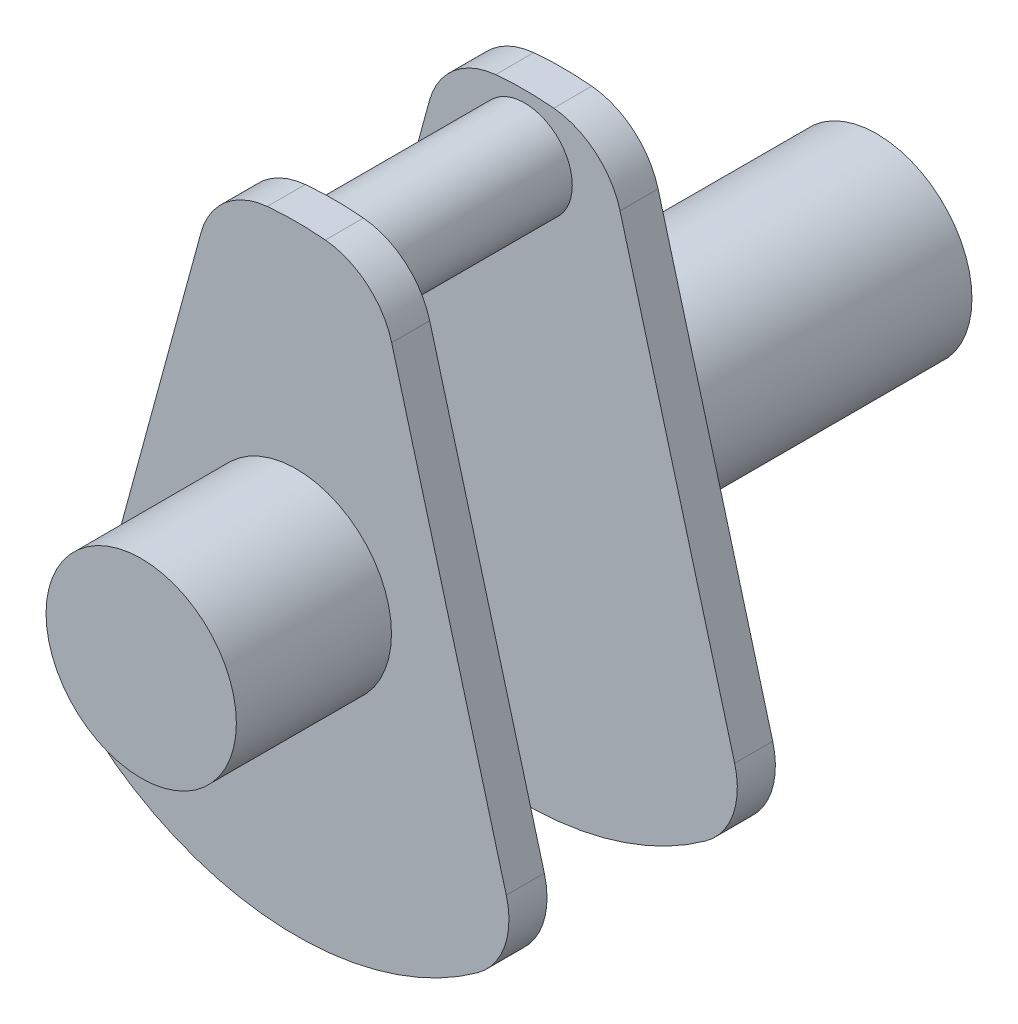
from build123d import *

# Parameters (mm, degrees)
BOSS_EXTRUDE1_DEPTH = 0.8
SKETCH2_R           = 1
BOSS_EXTRUDE2_DEPTH = 2
SKETCH3_R           = 2
BOSS_EXTRUDE3_DEPTH = 3.26
SKETCH4_R           = 2
BOSS_EXTRUDE4_DEPTH = 3.34
SKETCH5_W           = 0.1
SKETCH5_H           = 0.5
CUT_EXTRUDE1_DEPTH  = 0.1


with BuildPart() as part:
    # Sketch1 → Boss-Extrude1 (new body)
    with BuildSketch(Plane.XY):
        with BuildLine():
            Line((-2.003843202, 5.298536735), (-4.412682198, -3.552198604))
            ThreePointArc((-4.412682198, -3.552198604), (-4.377352827, -4.505653519), (-3.805602751, -5.269476986))
            ThreePointArc((-3.805602751, -5.269476986), (0, -6.5), (3.805602751, -5.269476986))
            ThreePointArc((3.805602751, -5.269476986), (4.377352827, -4.505653519), (4.412682198, -3.552198604))
            Line((4.412682198, -3.552198604), (2.003843202, 5.298536735))
            ThreePointArc((2.003843202, 5.298536735), (1.490188902, 6.102578835), (0.610204082, 6.471294382))
            ThreePointArc((0.610204082, 6.471294382), (0, 6.5), (-0.610204082, 6.471294382))
            ThreePointArc((-0.610204082, 6.471294382), (-1.490188902, 6.102578835), (-2.003843202, 5.298536735))
        make_face()
    extrude(amount=BOSS_EXTRUDE1_DEPTH)

    # Sketch2 → Boss-Extrude2 (add)
    with BuildSketch(Plane.XY.offset(0.8)):
        with Locations((0, 5.26)):
            Circle(SKETCH2_R)
    extrude(amount=BOSS_EXTRUDE2_DEPTH)

    # Sketch3 → Boss-Extrude3 (add)
    with BuildSketch(Plane(origin=(0, 0, 0), x_dir=(-1, 0, 0), z_dir=(0, 0, -1))):
        Circle(SKETCH3_R)
    extrude(amount=BOSS_EXTRUDE3_DEPTH)

    # Mirror1: part across plane


with BuildPart() as part_1:
    add(part.part)
    add(part.part.mirror(Plane(origin=(0, 5.26, 2.8), x_dir=(1, 0, 0), z_dir=(0, 0, 1))))

    # Sketch4 → Boss-Extrude4 (add)
    with BuildSketch(Plane(origin=(0, 0, -3.26), x_dir=(-1, 0, 0), z_dir=(0, 0, -1))):
        Circle(SKETCH4_R)
    extrude(amount=BOSS_EXTRUDE4_DEPTH)

    # Sketch5 → Cut-Extrude1 (cut)
    with BuildSketch(Plane(origin=(0, 0, 0), x_dir=(-1, 0, 0), z_dir=(0, 0, -1))):
        with Locations((0.05, 2.269348072)):
            Rectangle(SKETCH5_W, SKETCH5_H)
    extrude(amount=-CUT_EXTRUDE1_DEPTH, mode=Mode.SUBTRACT)


solid = part_1.part
